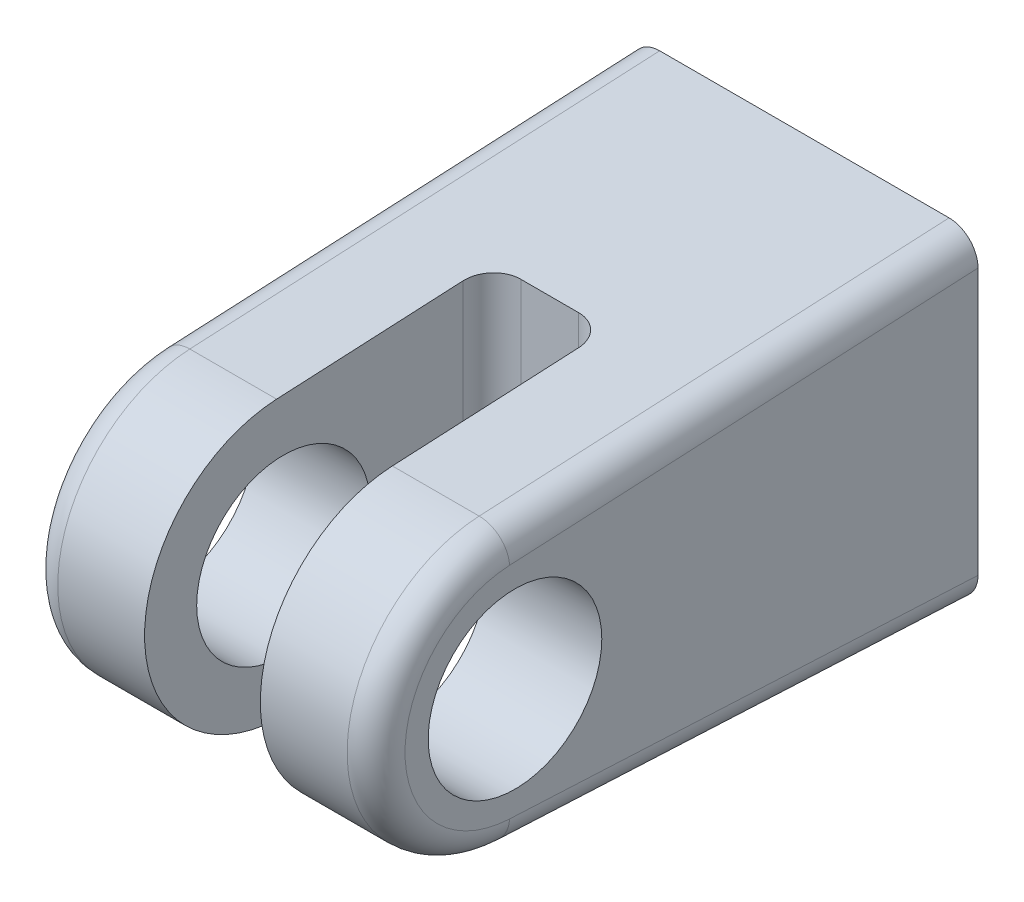
from build123d import *

# Parameters (mm, degrees)
EXTRUDE2_DEPTH          = 9.525
SKETCH3_W               = 6.35
SKETCH3_H               = 19.05
CUT_EXTRUDE1_DEPTH      = 9.89
CUT_EXTRUDE1_DEPTH_BACK = 9.89
SKETCH4_R               = 4.7625
CUT_EXTRUDE2_DEPTH      = 20.05
SKETCH5_R               = 6.35
CUT_EXTRUDE3_DEPTH      = 9.525
FILLET1_R               = 1.5875


with BuildPart() as part:
    # Sketch2 → Extrude2 (new body, symmetric)
    with BuildSketch(Plane(origin=(0, 0, 0), x_dir=(0, 0, -1), z_dir=(1, 0, 0))):
        with BuildLine():
            Line((0, 8.89), (-25.777721364, 7.610632469))
            ThreePointArc((-25.777721364, 7.610632469), (-33.02, 0), (-25.777721364, -7.610632469))
            Line((-25.777721364, -7.610632469), (0, -8.89))
            Line((0, -8.89), (0, 8.89))
        make_face()
    extrude(amount=EXTRUDE2_DEPTH, both=True)

    # Sketch3 → Cut-Extrude1 (cut, two sides)
    with BuildSketch(Plane(origin=(0, 0, 0), x_dir=(1, 0, 0), z_dir=(0, 1, 0))) as cut_extrude1_sk:
        with Locations((0, -23.495)):
            Rectangle(SKETCH3_W, SKETCH3_H)
    extrude(amount=CUT_EXTRUDE1_DEPTH, mode=Mode.SUBTRACT)
    extrude(cut_extrude1_sk.sketch, amount=-CUT_EXTRUDE1_DEPTH_BACK, mode=Mode.SUBTRACT)

    # Sketch4 → Cut-Extrude2 (cut, through all)
    with BuildSketch(Plane(origin=(9.525, 0, 0), x_dir=(0, 0, -1), z_dir=(1, 0, 0))):
        with Locations((-25.4, 0)):
            Circle(SKETCH4_R)
    extrude(amount=-CUT_EXTRUDE2_DEPTH, mode=Mode.SUBTRACT)

    # Sketch5 → Cut-Extrude3 (cut)
    with BuildSketch(Plane(origin=(0, 0, 0), x_dir=(-1, 0, 0), z_dir=(0, 0, -1))):
        Circle(SKETCH5_R)
    extrude(amount=-CUT_EXTRUDE3_DEPTH, mode=Mode.SUBTRACT)

    # Fillet1
    fillet1_edges = [part.edges().sort_by_distance(p)[0] for p in [
        (9.525, 0, 33.02),
        (9.525, -8.250316234, 12.888860682),
        (-3.175, 0, 13.97),
        (3.175, 0, 13.97),
        (-9.525, -8.250316234, 12.888860682),
        (-9.525, 0, 33.02),
        (-9.525, 8.250316234, 12.888860682),
        (9.525, 8.250316234, 12.888860682),
    ]]
    fillet(fillet1_edges, radius=FILLET1_R)


solid = part.part
